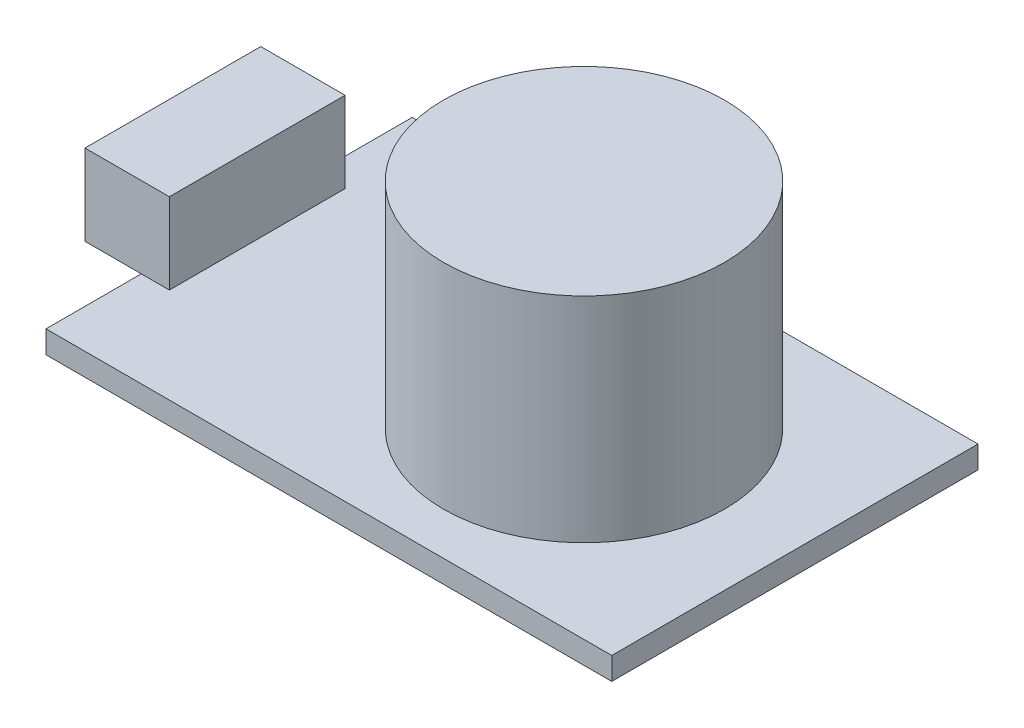
from build123d import *

# Parameters (mm, degrees)
SKETCH_1_W           = 40.24
SKETCH_1_H           = 26.05
EXTRUDE_1_DEPTH      = 1.6
EXTRUDE_2_DEPTH      = 15.2
EXTRUDE_3_DEPTH      = 4
EXTRUDE_3_DEPTH_BACK = 2


with BuildPart() as part:
    # 草图1 → 凸台-拉伸1 (new body)
    with BuildSketch(Plane(origin=(0, 0, 0), x_dir=(1, 0, 0), z_dir=(0, 1, 0))):
        with Locations((20.12, 13.025)):
            Rectangle(SKETCH_1_W, SKETCH_1_H)
    extrude(amount=EXTRUDE_1_DEPTH)

    # 草图2 → 凸台-拉伸2 (add)
    with BuildSketch(Plane(origin=(0, 1.6, 0), x_dir=(1, 0, 0), z_dir=(0, 1, 0))):
        with BuildLine():
            Line((15.24, 13.025), (25.24, 13.025))
            Line((25.24, 13.025), (35.24, 13.025))
            ThreePointArc((35.24, 13.025), (25.24, 23.025), (15.24, 13.025))
        make_face()
        with BuildLine():
            Line((35.24, 13.025), (25.24, 13.025))
            Line((25.24, 13.025), (15.24, 13.025))
            ThreePointArc((15.24, 13.025), (25.24, 3.025), (35.24, 13.025))
        make_face()
    extrude(amount=EXTRUDE_2_DEPTH)

    # 草图3 → 凸台-拉伸3 (add, two sides)
    with BuildSketch(Plane.ZY) as extrude_3_sk:
        Polygon((-19.275, 7.35), (-19.275, 1.6), (-13.025, 1.6), (-6.775, 1.6), (-6.775, 7.35), align=None)
    extrude(amount=EXTRUDE_3_DEPTH)
    extrude(extrude_3_sk.sketch, amount=-EXTRUDE_3_DEPTH_BACK)


solid = part.part
